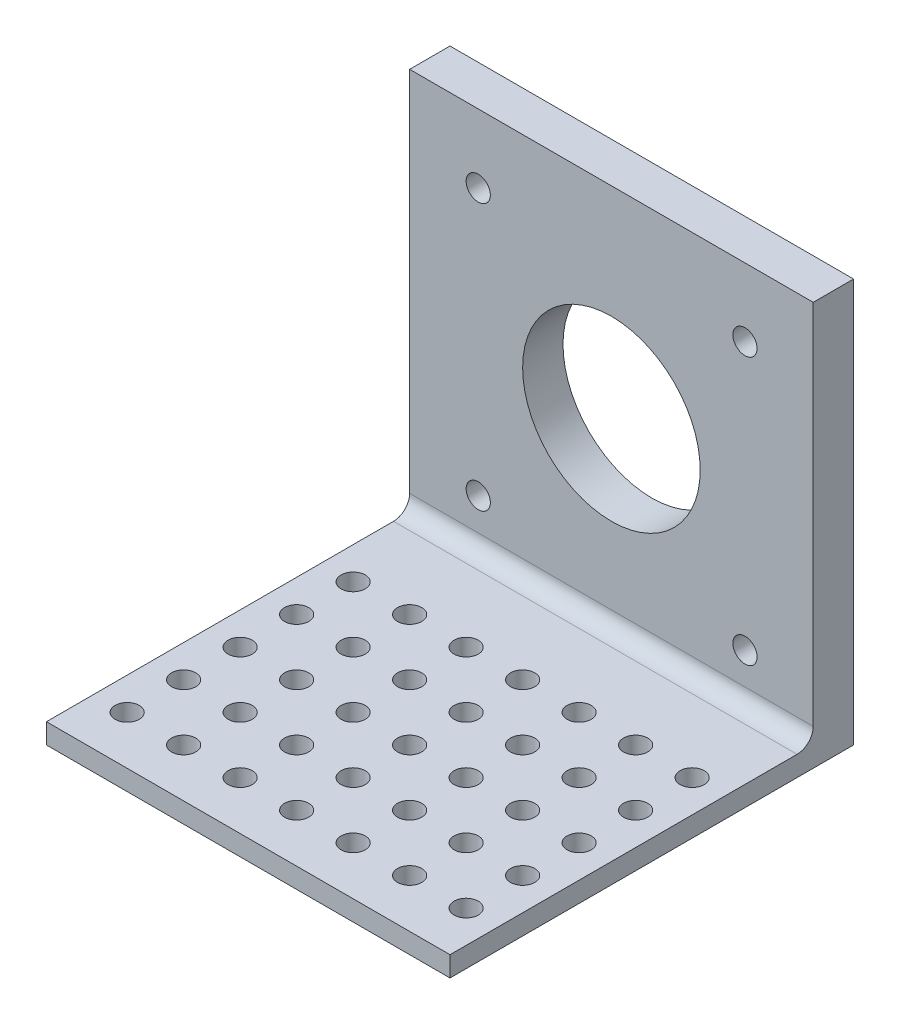
from build123d import *

# Parameters (mm, degrees)
ESBO_O1_W                = 50
ESBO_O1_H                = 50
ESBO_O1_R                = 11
ESBO_O1_R_2              = 1.5
RESSALTO_EXTRUS_O1_DEPTH = 10
ESBO_O2_W                = 50
ESBO_O2_H                = 2.5
RESSALTO_EXTRUS_O2_DEPTH = 50
ESBO_O3_R                = 1.5
CORTE_EXTRUS_O1_DEPTH    = 101
ESBO_O1_2_W              = 50
ESBO_O1_2_H              = 50
ESBO_O1_2_R              = 11
ESBO_O1_2_R_2            = 1.5
RESSALTO_EXTRUS_O3_DEPTH = 4
ESBO_O5_W                = 50
ESBO_O5_H                = 5
CORTE_EXTRUS_O2_DEPTH    = 47.5
FILETE2_R                = 2


with BuildPart() as part:
    # Esboço1 → Ressalto-extrusão1 (new body)
    with BuildSketch(Plane.XY):
        with Locations((25, -25)):
            Rectangle(ESBO_O1_W, ESBO_O1_H)
        with Locations((25, -25)):
            Circle(ESBO_O1_R, mode=Mode.SUBTRACT)
        with Locations((8.5, -8.5)):
            Circle(ESBO_O1_R_2, mode=Mode.SUBTRACT)
        with Locations((41.546450715, -8.453549285)):
            Circle(ESBO_O1_R_2, mode=Mode.SUBTRACT)
        with Locations((41.546450715, -41.546450715)):
            Circle(ESBO_O1_R_2, mode=Mode.SUBTRACT)
        with Locations((8.5, -41.5)):
            Circle(ESBO_O1_R_2, mode=Mode.SUBTRACT)
    extrude(amount=RESSALTO_EXTRUS_O1_DEPTH)

    # Esboço2 → Ressalto-extrusão2 (add)
    with BuildSketch(Plane.XY):
        with Locations((25, -48.75)):
            Rectangle(ESBO_O2_W, ESBO_O2_H)
    extrude(amount=RESSALTO_EXTRUS_O2_DEPTH)

    # Esboço3 → Corte-extrusão1 (cut)
    with BuildSketch(Plane(origin=(0, 0, 0), x_dir=(1, 0, 0), z_dir=(0, 1, 0))):
        with Locations((4, -37)):
            Circle(ESBO_O3_R)
        with Locations((4, -44)):
            Circle(ESBO_O3_R)
        with Locations((11, -44)):
            Circle(ESBO_O3_R)
        with Locations((18, -44)):
            Circle(ESBO_O3_R)
        with Locations((25, -44)):
            Circle(ESBO_O3_R)
        with Locations((32, -44)):
            Circle(ESBO_O3_R)
        with Locations((39, -44)):
            Circle(ESBO_O3_R)
        with Locations((46, -44)):
            Circle(ESBO_O3_R)
        with Locations((46, -37)):
            Circle(ESBO_O3_R)
        with Locations((39, -37)):
            Circle(ESBO_O3_R)
        with Locations((32, -37)):
            Circle(ESBO_O3_R)
        with Locations((25, -37)):
            Circle(ESBO_O3_R)
        with Locations((18, -37)):
            Circle(ESBO_O3_R)
        with Locations((11, -37)):
            Circle(ESBO_O3_R)
        with Locations((4, -30)):
            Circle(ESBO_O3_R)
        with Locations((11, -30)):
            Circle(ESBO_O3_R)
        with Locations((18, -30)):
            Circle(ESBO_O3_R)
        with Locations((32, -30)):
            Circle(ESBO_O3_R)
        with Locations((25, -30)):
            Circle(ESBO_O3_R)
        with Locations((39, -30)):
            Circle(ESBO_O3_R)
        with Locations((46, -30)):
            Circle(ESBO_O3_R)
        with Locations((46, -23)):
            Circle(ESBO_O3_R)
        with Locations((39, -23)):
            Circle(ESBO_O3_R)
        with Locations((32, -23)):
            Circle(ESBO_O3_R)
        with Locations((18, -23)):
            Circle(ESBO_O3_R)
        with Locations((25, -23)):
            Circle(ESBO_O3_R)
        with Locations((11, -23)):
            Circle(ESBO_O3_R)
        with Locations((4, -23)):
            Circle(ESBO_O3_R)
        with Locations((4, -16)):
            Circle(ESBO_O3_R)
        with Locations((11, -16)):
            Circle(ESBO_O3_R)
        with Locations((18, -16)):
            Circle(ESBO_O3_R)
        with Locations((25, -16)):
            Circle(ESBO_O3_R)
        with Locations((32, -16)):
            Circle(ESBO_O3_R)
        with Locations((39, -16)):
            Circle(ESBO_O3_R)
        with Locations((46, -16)):
            Circle(ESBO_O3_R)
    extrude(amount=-CORTE_EXTRUS_O1_DEPTH, mode=Mode.SUBTRACT)

    # Esboço1<2> → Ressalto-extrusão3 (add)
    with BuildSketch(Plane.XY):
        with Locations((25, -25)):
            Rectangle(ESBO_O1_2_W, ESBO_O1_2_H)
        with Locations((25, -25)):
            Circle(ESBO_O1_2_R, mode=Mode.SUBTRACT)
        with Locations((8.5, -8.5)):
            Circle(ESBO_O1_2_R_2, mode=Mode.SUBTRACT)
        with Locations((41.546450715, -8.453549285)):
            Circle(ESBO_O1_2_R_2, mode=Mode.SUBTRACT)
        with Locations((41.546450715, -41.546450715)):
            Circle(ESBO_O1_2_R_2, mode=Mode.SUBTRACT)
        with Locations((8.5, -41.5)):
            Circle(ESBO_O1_2_R_2, mode=Mode.SUBTRACT)
    extrude(amount=RESSALTO_EXTRUS_O3_DEPTH)

    # Esboço5 → Corte-extrusão2 (cut)
    with BuildSketch(Plane(origin=(0, 0, 0), x_dir=(1, 0, 0), z_dir=(0, 1, 0))):
        with Locations((25, -7.5)):
            Rectangle(ESBO_O5_W, ESBO_O5_H)
    extrude(amount=-CORTE_EXTRUS_O2_DEPTH, mode=Mode.SUBTRACT)

    # Filete2
    filete2_edges = [part.edges().sort_by_distance(p)[0] for p in [
        (25, -47.5, 5),
    ]]
    fillet(filete2_edges, radius=FILETE2_R)


solid = part.part
